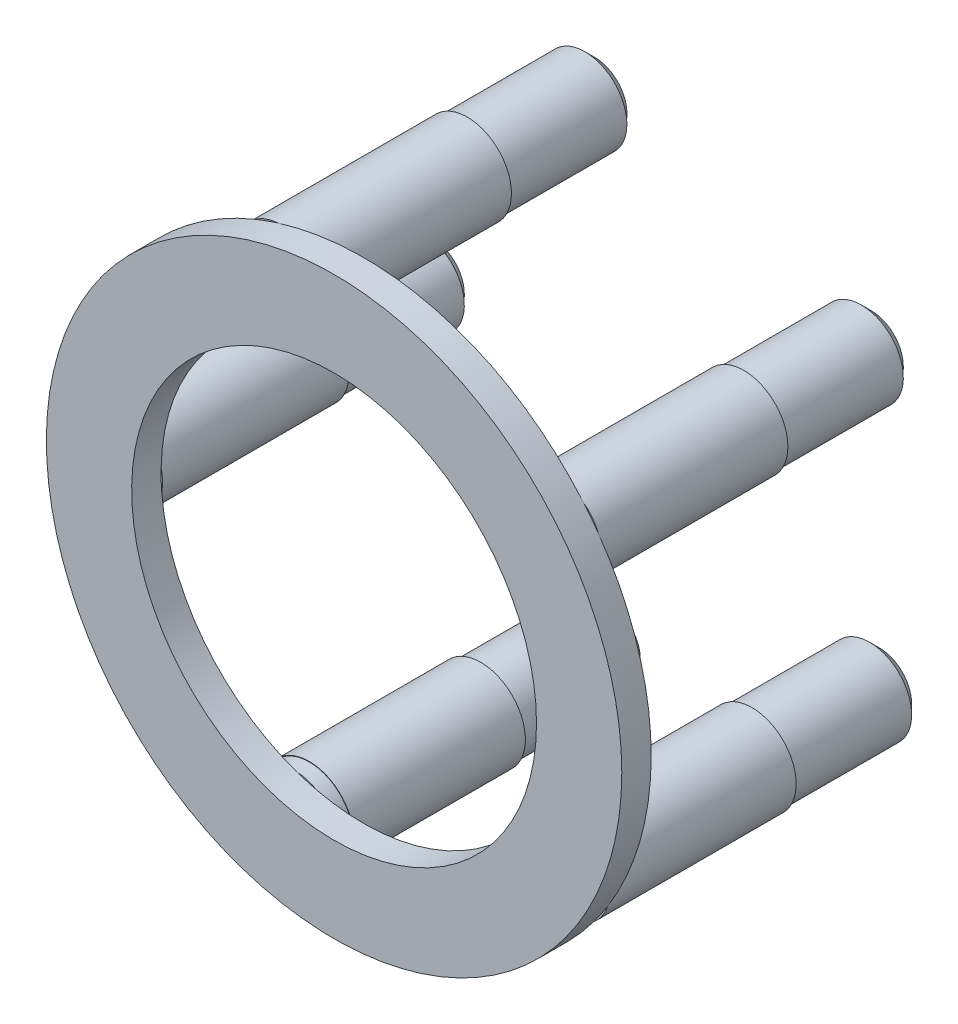
from build123d import *

# Parameters (mm, degrees)
SKETCH2_R             = 4.5
BOSS_EXTRUDE1_DEPTH   = 30
BOSS_EXTRUDE1_2_DEPTH = 30
BOSS_EXTRUDE1_3_DEPTH = 30
BOSS_EXTRUDE1_4_DEPTH = 30
BOSS_EXTRUDE1_5_DEPTH = 30
SKETCH3_R             = 29.35
SKETCH3_R_2           = 20.65
BOSS_EXTRUDE2_DEPTH   = 3
SKETCH4_R             = 4.5
BOSS_EXTRUDE3_DEPTH   = 2
SKETCH5_R             = 4.5
SKETCH5_R_2           = 4.275
CUT_EXTRUDE1_DEPTH    = 13
CHAMFER1_SIZE         = 1
SKETCH6_R             = 4.55
BOSS_EXTRUDE4_DEPTH   = 17.5


with BuildPart() as part:
    # Sketch2 → Boss-Extrude1 (new body)
    with BuildSketch(Plane(origin=(0, 0, -6.013631981), x_dir=(-1, 0, 0), z_dir=(0, 0, -1))):
        with Locations((-11.73472812, -13.580511576)):
            Circle(SKETCH2_R)
    extrude(amount=BOSS_EXTRUDE1_DEPTH)



with BuildPart() as body_2:
    # Sketch2 → Boss-Extrude1 2 (new body)
    with BuildSketch(Plane(origin=(0, 0, -6.013631981), x_dir=(-1, 0, 0), z_dir=(0, 0, -1))):
        with Locations((4.847454424, -37.844888326)):
            Circle(SKETCH2_R)
    extrude(amount=BOSS_EXTRUDE1_2_DEPTH)


with BuildPart() as body_3:
    # Sketch2 → Boss-Extrude1 3 (new body)
    with BuildSketch(Plane(origin=(0, 0, -6.013631981), x_dir=(-1, 0, 0), z_dir=(0, 0, -1))):
        with Locations((-13.105162988, -61.113585864)):
            Circle(SKETCH2_R)
    extrude(amount=BOSS_EXTRUDE1_3_DEPTH)


with BuildPart() as body_4:
    # Sketch2 → Boss-Extrude1 4 (new body)
    with BuildSketch(Plane(origin=(0, 0, -6.013631981), x_dir=(-1, 0, 0), z_dir=(0, 0, -1))):
        with Locations((-40.78267328, -51.230055065)):
            Circle(SKETCH2_R)
    extrude(amount=BOSS_EXTRUDE1_4_DEPTH)


with BuildPart() as body_5:
    # Sketch2 → Boss-Extrude1 5 (new body)
    with BuildSketch(Plane(origin=(0, 0, -6.013631981), x_dir=(-1, 0, 0), z_dir=(0, 0, -1))):
        with Locations((-39.935697953, -21.852999565)):
            Circle(SKETCH2_R)
    extrude(amount=BOSS_EXTRUDE1_5_DEPTH)


with BuildPart() as part_1:
    add(part.part)

    add(body_2.part)  # Boss-Extrude2 merges body 2

    add(body_3.part)  # Boss-Extrude2 merges body 3

    add(body_4.part)  # Boss-Extrude2 merges body 4

    add(body_5.part)  # Boss-Extrude2 merges body 5
    # Sketch3 → Boss-Extrude2 (add)
    with BuildSketch(Plane.XY.offset(-6.013631981)):
        with Locations((20.142161583, -37.124408079)):
            Circle(SKETCH3_R)
        with Locations((20.142161583, -37.124408079)):
            Circle(SKETCH3_R_2, mode=Mode.SUBTRACT)
    extrude(amount=BOSS_EXTRUDE2_DEPTH)

    # Sketch4 → Boss-Extrude3 (add)
    with BuildSketch(Plane(origin=(0, 0, -36.013631981), x_dir=(-1, 0, 0), z_dir=(0, 0, -1))):
        with Locations((4.847454424, -37.844888326)):
            Circle(SKETCH4_R)
        with Locations((-11.73472812, -13.580511576)):
            Circle(SKETCH4_R)
        with Locations((-39.935697953, -21.852999565)):
            Circle(SKETCH4_R)
        with Locations((-40.78267328, -51.230055065)):
            Circle(SKETCH4_R)
        with Locations((-13.105162988, -61.113585864)):
            Circle(SKETCH4_R)
    extrude(amount=BOSS_EXTRUDE3_DEPTH)

    # Sketch5 → Cut-Extrude1 (cut)
    with BuildSketch(Plane(origin=(0, 0, -38.013631981), x_dir=(-1, 0, 0), z_dir=(0, 0, -1))):
        with Locations((-13.105162988, -61.113585864)):
            Circle(SKETCH5_R)
        with Locations((-13.105162988, -61.113585864)):
            Circle(SKETCH5_R_2, mode=Mode.SUBTRACT)
        with Locations((-40.78267328, -51.230055065)):
            Circle(SKETCH5_R)
        with Locations((-40.78267328, -51.230055065)):
            Circle(SKETCH5_R_2, mode=Mode.SUBTRACT)
        with Locations((-39.935697953, -21.852999565)):
            Circle(SKETCH5_R)
        with Locations((-39.935697953, -21.852999565)):
            Circle(SKETCH5_R_2, mode=Mode.SUBTRACT)
        with Locations((-11.73472812, -13.580511576)):
            Circle(SKETCH5_R)
        with Locations((-11.73472812, -13.580511576)):
            Circle(SKETCH5_R_2, mode=Mode.SUBTRACT)
        with Locations((4.847454424, -37.844888326)):
            Circle(SKETCH5_R)
        with Locations((4.847454424, -37.844888326)):
            Circle(SKETCH5_R_2, mode=Mode.SUBTRACT)
    extrude(amount=-CUT_EXTRUDE1_DEPTH, mode=Mode.SUBTRACT)

    # Chamfer1
    chamfer1_edges = [part_1.edges().sort_by_distance(p)[0] for p in [
        (17.380162988, -61.113585864, -38.013631981),
        (45.05767328, -51.230055065, -38.013631981),
        (44.210697953, -21.852999565, -38.013631981),
        (16.00972812, -13.580511576, -38.013631981),
        (-0.572454424, -37.844888326, -38.013631981),
    ]]
    chamfer(chamfer1_edges, length=CHAMFER1_SIZE)

    # Sketch6 → Boss-Extrude4 (add)
    with BuildSketch(Plane(origin=(0, 0, -25.013631981), x_dir=(-1, 0, 0), z_dir=(0, 0, -1))):
        with Locations((-13.105162988, -61.113585864)):
            Circle(SKETCH6_R)
    extrude(amount=-BOSS_EXTRUDE4_DEPTH)


solid = part_1.part
